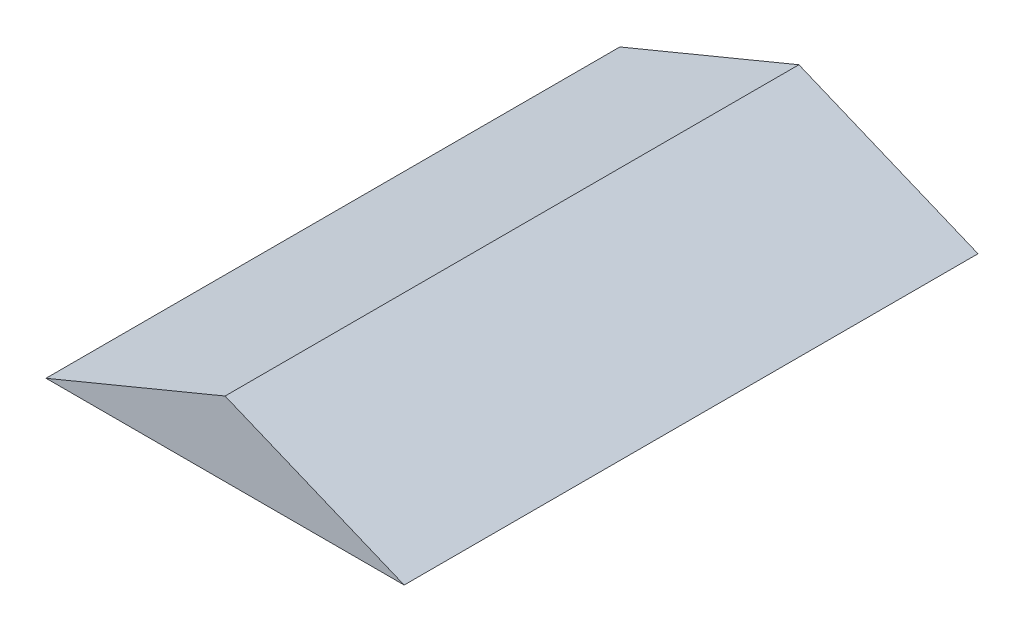
from build123d import *

# Parameters (mm, degrees)
EXTRUDE_1_DEPTH = 80.1


with BuildPart() as part:
    # 草圖1 → 填料-伸長1 (new body)
    with BuildSketch(Plane.XY):
        Polygon((-25.36145523, -17.614402599), (24.63854477, -17.614402599), (-0.362306503, -7.264402599), align=None)
    extrude(amount=EXTRUDE_1_DEPTH)


solid = part.part
